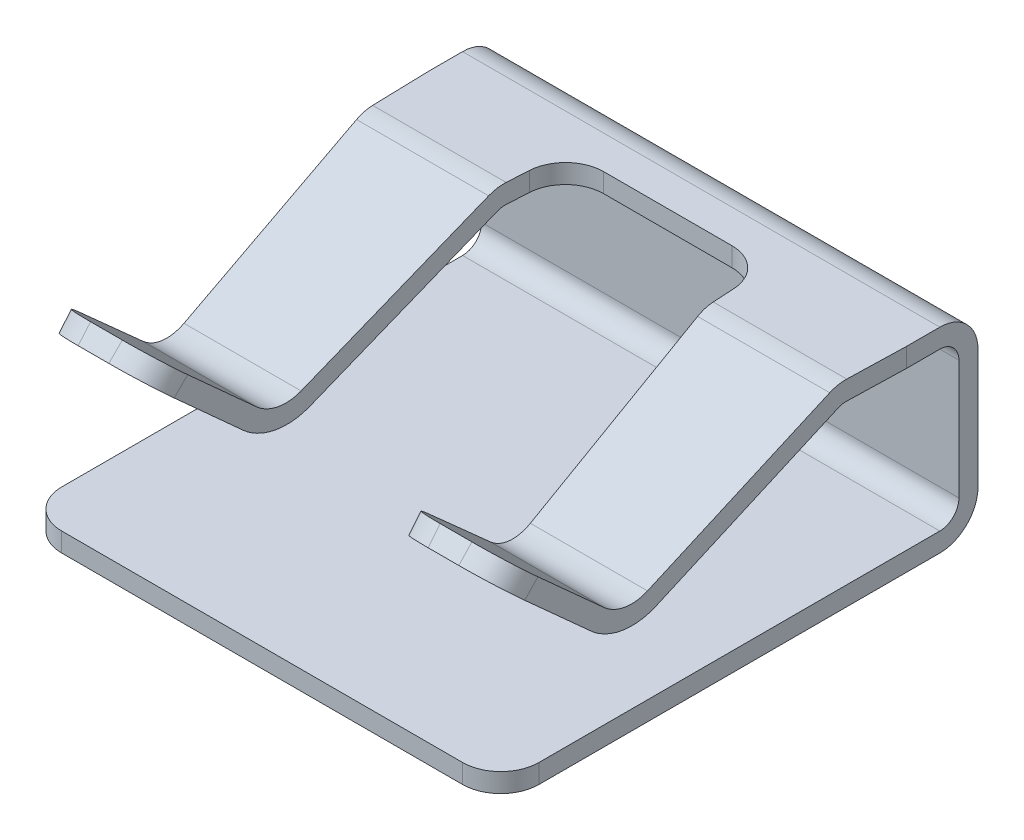
from build123d import *

# Parameters (mm, degrees)
BOSS_EXTRUDE1_DEPTH = 2.5
CUT_EXTRUDE1_DEPTH  = 1.5
FILLET1_R           = 0.4


with BuildPart() as part:
    # Sketch1 → Boss-Extrude1 (new body, symmetric)
    with BuildSketch(Plane(origin=(0, 0, 0), x_dir=(0, 0, -1), z_dir=(1, 0, 0))):
        with BuildLine():
            Line((0, 0.4), (0, 1.65))
            ThreePointArc((0, 1.65), (-0.117157288, 1.932842712), (-0.4, 2.05))
            Line((-0.4, 2.05), (-1.358780422, 2.05))
            ThreePointArc((-1.358780422, 2.05), (-1.447716686, 2.039987616), (-1.532200631, 2.010451704))
            Line((-1.532200631, 2.010451704), (-3.390846854, 1.116221457))
            ThreePointArc((-3.390846854, 1.116221457), (-3.620875047, 1.080699), (-3.831736196, 1.17925046))
            Line((-3.831736196, 1.17925046), (-4.8, 2.05))
            Line((-4.8, 2.05), (-4.933734566, 1.90128865))
            Line((-4.933734566, 1.90128865), (-3.965470763, 1.03053911))
            ThreePointArc((-3.965470763, 1.03053911), (-3.649179039, 0.88271192), (-3.30413675, 0.935995605))
            Line((-3.30413675, 0.935995605), (-1.445490526, 1.830225852))
            ThreePointArc((-1.445490526, 1.830225852), (-1.403248554, 1.844993808), (-1.358780422, 1.85))
            Line((-1.358780422, 1.85), (-0.4, 1.85))
            ThreePointArc((-0.4, 1.85), (-0.258578644, 1.791421356), (-0.2, 1.65))
            Line((-0.2, 1.65), (-0.2, 0.4))
            ThreePointArc((-0.2, 0.4), (-0.258578644, 0.258578644), (-0.4, 0.2))
            Line((-0.4, 0.2), (-5, 0.2))
            Line((-5, 0.2), (-5, 0))
            Line((-5, 0), (-0.4, 0))
            ThreePointArc((-0.4, 0), (-0.117157288, 0.117157288), (0, 0.4))
        make_face()
    extrude(amount=BOSS_EXTRUDE1_DEPTH, both=True)

    # Sketch2 → Cut-Extrude1 (cut)
    with BuildSketch(Plane(origin=(0, 2.05, 0), x_dir=(1, 0, 0), z_dir=(0, 1, 0))):
        Polygon((-1.05, -0.75), (1.05, -0.75), (1.289010448, -4.933734566), (-1.289010448, -4.933734566), align=None)
        Polygon((-2.5, -0.75), (-2.5, -4.933734566), (-2.386118968, -4.933734566), align=None)
        Polygon((2.5, -4.933734566), (2.386118968, -4.933734566), (2.5, -0.75), align=None)
    extrude(amount=-CUT_EXTRUDE1_DEPTH, mode=Mode.SUBTRACT)

    # Fillet1
    fillet1_edges = [part.edges().sort_by_distance(p)[0] for p in [
        (2.387939092, 1.975644325, 4.866867283),
        (-1.05, 1.95, 0.75),
        (1.05, 1.95, 0.75),
        (1.285190421, 1.975644325, 4.866867283),
        (-1.285190421, 1.975644325, 4.866867283),
        (-2.5, 0.1, 5),
        (2.5, 0.1, 5),
        (-2.387939092, 1.975644325, 4.866867283),
    ]]
    fillet(fillet1_edges, radius=FILLET1_R)


solid = part.part
